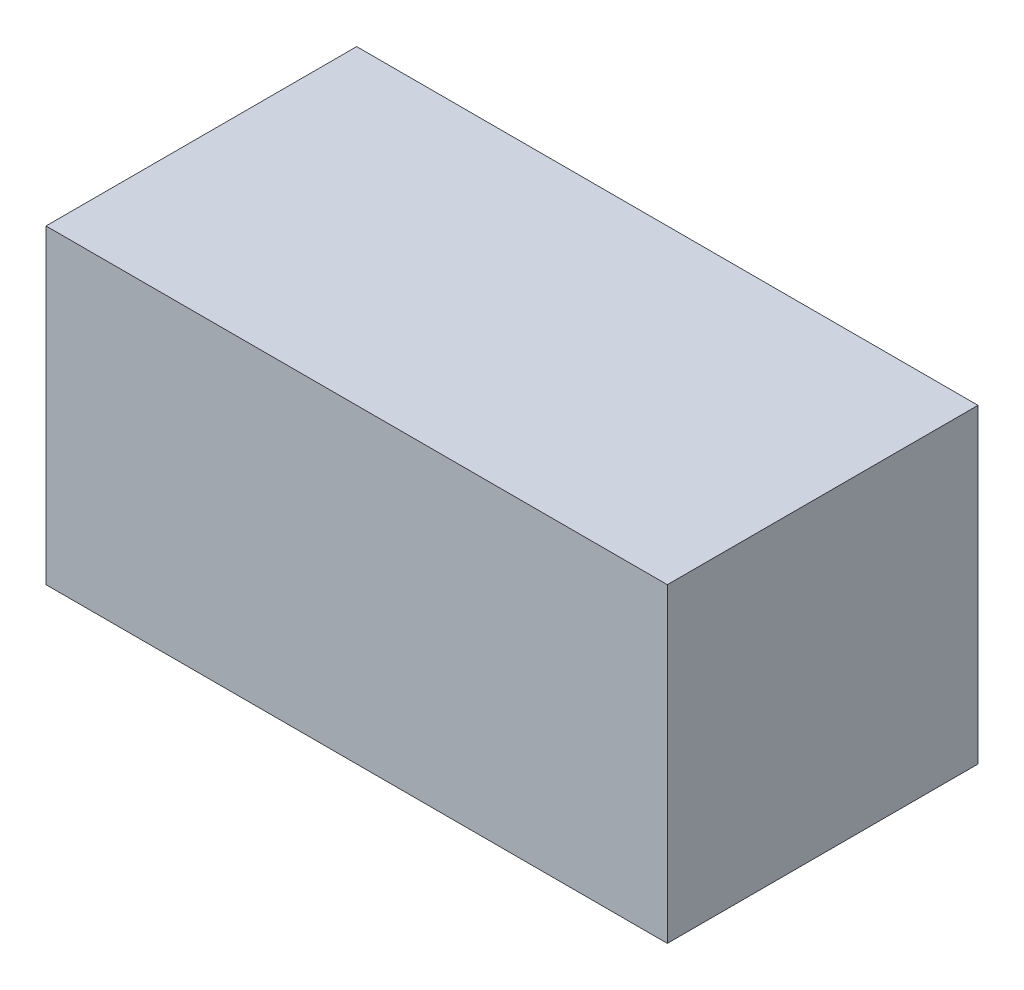
from build123d import *

# Parameters (mm, degrees)
SKETCH_1_W      = 300
SKETCH_1_H      = 150
EXTRUDE_1_DEPTH = 150


with BuildPart() as part:
    # ｽｹｯﾁ1 → ﾎﾞｽ - 押し出し1 (new body)
    with BuildSketch(Plane(origin=(0, 0, 0), x_dir=(1, 0, 0), z_dir=(0, 1, 0))):
        Rectangle(SKETCH_1_W, SKETCH_1_H)
    extrude(amount=EXTRUDE_1_DEPTH)


solid = part.part
